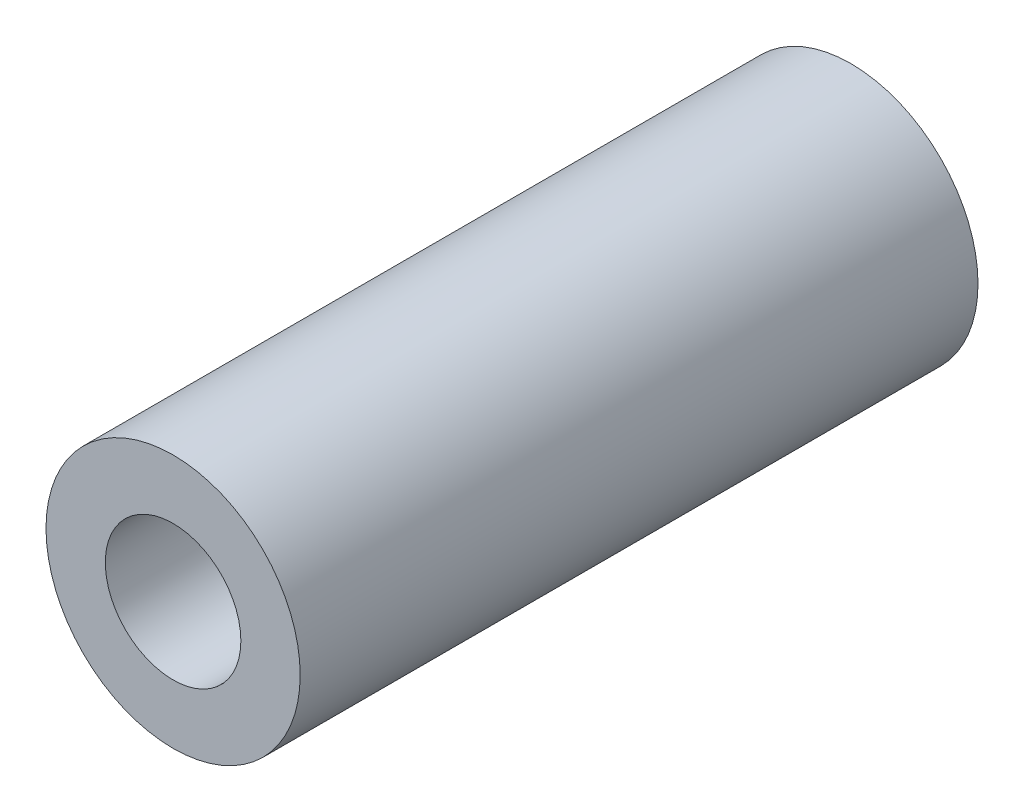
from build123d import *

# Parameters (mm, degrees)
SKETCH_1_R      = 3
SKETCH_1_R_2    = 1.6
EXTRUDE_1_DEPTH = 16


with BuildPart() as part:
    # ｽｹｯﾁ1 → ﾎﾞｽ - 押し出し1 (new body)
    with BuildSketch(Plane.XY):
        Circle(SKETCH_1_R)
        Circle(SKETCH_1_R_2, mode=Mode.SUBTRACT)
    extrude(amount=EXTRUDE_1_DEPTH)


solid = part.part
